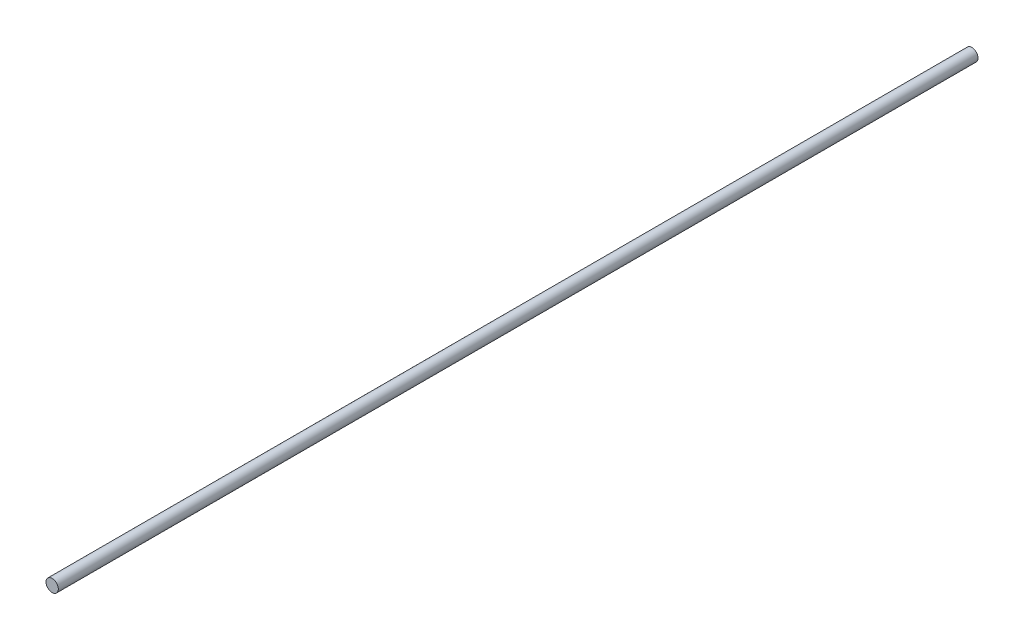
from build123d import *

# Parameters (mm, degrees)
SKETCH1_R           = 11.049
BOSS_EXTRUDE1_DEPTH = 825.5


with BuildPart() as part:
    # Sketch1 → Boss-Extrude1 (new body, symmetric)
    with BuildSketch(Plane.XY):
        Circle(SKETCH1_R)
    extrude(amount=BOSS_EXTRUDE1_DEPTH, both=True)


solid = part.part
